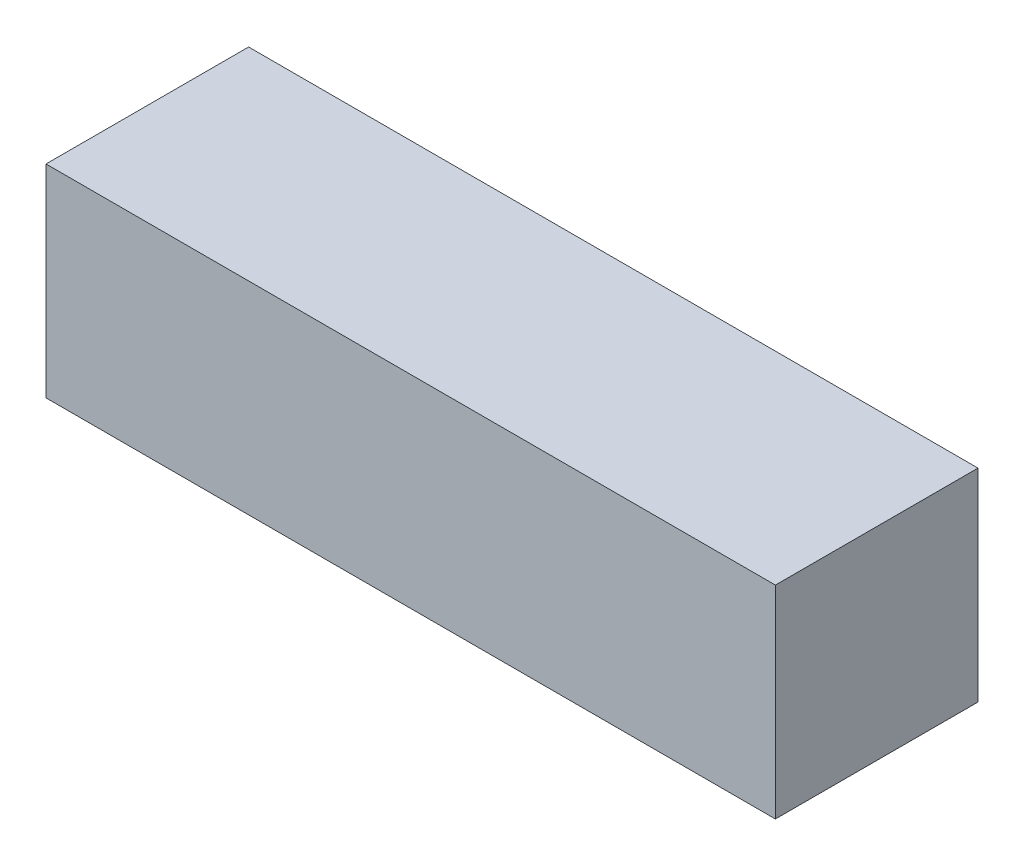
from build123d import *

# Parameters (mm, degrees)
SKETCH_1_W      = 36
SKETCH_1_H      = 10
EXTRUDE_1_DEPTH = 10


with BuildPart() as part:
    # 草圖1 → 填料-伸長1 (new body)
    with BuildSketch(Plane.XY):
        with Locations((-6.09430438, 3.213709677)):
            Rectangle(SKETCH_1_W, SKETCH_1_H)
    extrude(amount=EXTRUDE_1_DEPTH)


solid = part.part
